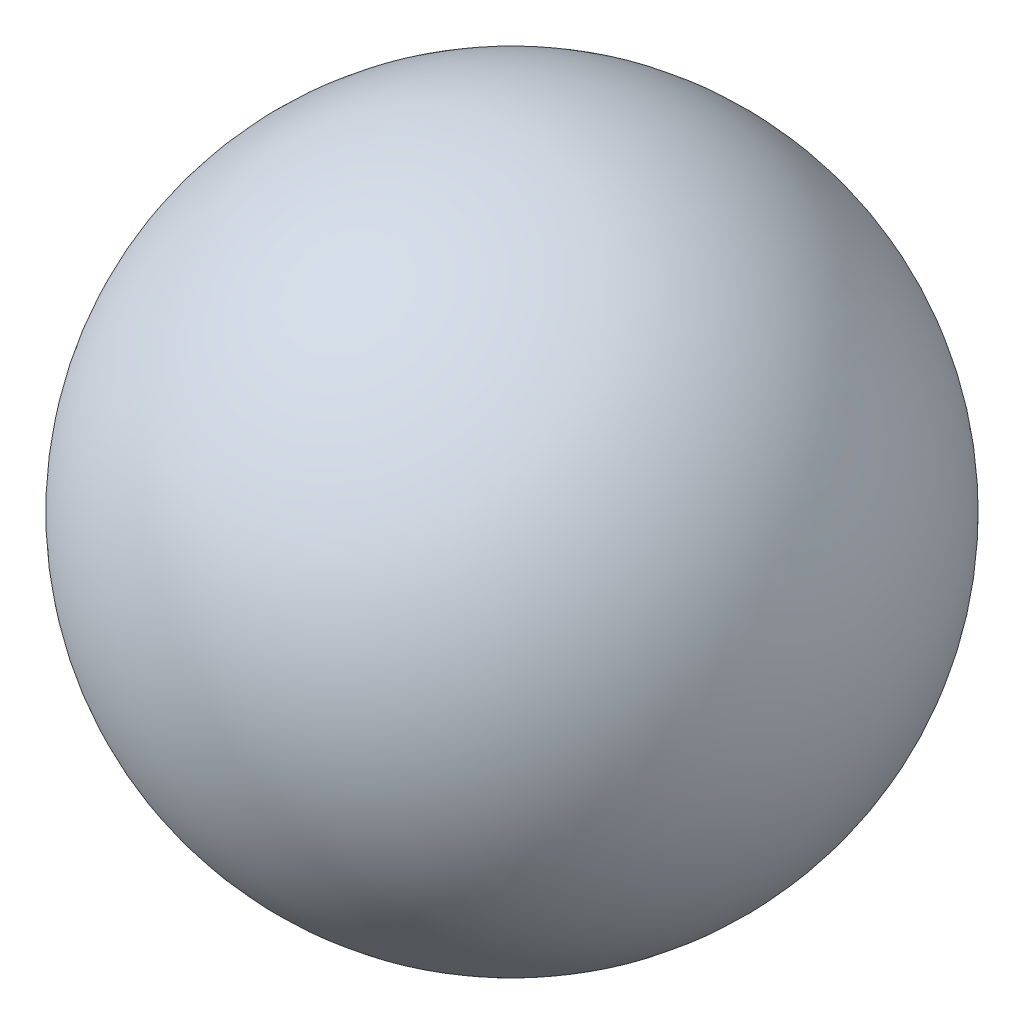
from build123d import *


with BuildPart() as part:
    # Sketch1 → Revolve1 (revolve)
    with BuildSketch(Plane.XY):
        with BuildLine():
            Line((0, -21.5), (0, 21.5))
            ThreePointArc((0, 21.5), (21.5, 0), (0, -21.5))
        make_face()
    revolve(axis=Axis((0, -21.5, 0), (0, 1, 0)))


solid = part.part
